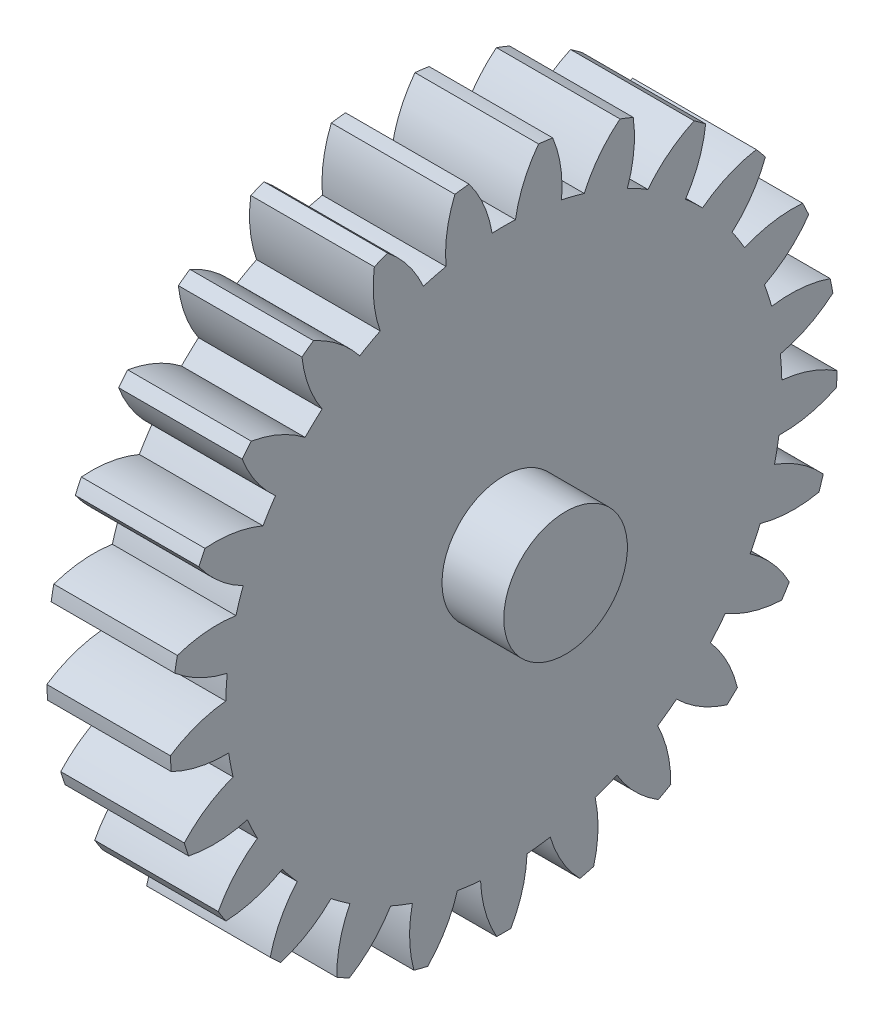
from build123d import *

# Parameters (mm, degrees)
SKETCH1_R                = 5
BOSS_EXTRUDE1_DEPTH      = 10
SKETCH2_R                = 5
BOSS_EXTRUDE2_DEPTH      = 5
BOSS_EXTRUDE2_DEPTH_BACK = 15


with BuildPart() as part:
    # Sketch1 → Boss-Extrude1 (new body)
    with BuildSketch(Plane(origin=(-8.184065019, 0, 0), x_dir=(0, 0, -1), z_dir=(1, 0, 0))):
        with BuildLine():
            ThreePointArc((-31.381707066, 6.680458214), (-29.386381489, 5.356012875), (-27.133369334, 4.54396864))
            ThreePointArc((-27.133369334, 4.54396864), (-27.212642826, 3.600930631), (-27.252188432, 2.655393156))
            ThreePointArc((-27.252188432, 2.655393156), (-29.589211043, 2.132129431), (-31.734799899, 1.068208346))
            ThreePointArc((-31.734799899, 1.068208346), (-31.70476113, 0.492862705), (-31.662453104, -0.081711019))
            ThreePointArc((-31.662453104, -0.081711019), (-29.400438188, -0.86832918), (-27.016261363, -1.094560213))
            ThreePointArc((-27.016261363, -1.094560213), (-26.858520317, -2.027685464), (-26.661677917, -2.953351734))
            ThreePointArc((-26.661677917, -2.953351734), (-28.795148269, -4.041370056), (-30.60874309, -5.605452354))
            ThreePointArc((-30.60874309, -5.605452354), (-30.436565403, -6.155252116), (-30.252695887, -6.701252972))
            ThreePointArc((-30.252695887, -6.701252972), (-27.866122347, -6.900617842), (-25.500587451, -6.526820746))
            ThreePointArc((-25.500587451, -6.526820746), (-25.115743316, -7.391401548), (-24.694881242, -8.239033595))
            ThreePointArc((-24.694881242, -8.239033595), (-26.490745546, -9.823442323), (-27.858391501, -11.789408791))
            ThreePointArc((-27.858391501, -11.789408791), (-27.554893451, -12.279116732), (-27.241015643, -12.762237478))
            ThreePointArc((-27.241015643, -12.762237478), (-24.879840672, -12.36182223), (-22.681582963, -11.411484051))
            ThreePointArc((-22.681582963, -11.411484051), (-22.093816912, -12.153195613), (-21.475379476, -12.869533599))
            ThreePointArc((-21.475379476, -12.869533599), (-22.820796972, -14.850778503), (-23.656559836, -17.095100238))
            ThreePointArc((-23.656559836, -17.095100238), (-23.240811323, -17.493946208), (-22.816647319, -17.88383059))
            ThreePointArc((-22.816647319, -17.88383059), (-20.629232225, -16.908794787), (-18.736376318, -15.441628767))
            ThreePointArc((-18.736376318, -15.441628767), (-17.982619854, -16.013866624), (-17.205465754, -16.553900399))
            ThreePointArc((-17.205465754, -16.553900399), (-18.015898914, -18.807492577), (-18.267264631, -21.189150589))
            ThreePointArc((-18.267264631, -21.189150589), (-17.765388663, -21.472073629), (-17.257590249, -21.744223778))
            ThreePointArc((-17.257590249, -21.744223778), (-15.381378366, -20.255832504), (-13.912859361, -18.364026081))
            ThreePointArc((-13.912859361, -18.364026081), (-13.040473774, -18.730834424), (-12.153434461, -19.060631679))
            ThreePointArc((-12.153434461, -19.060631679), (-12.377960788, -21.444969646), (-12.029135127, -23.814315604))
            ThreePointArc((-12.029135127, -23.814315604), (-11.472666416, -23.963538618), (-10.913140433, -24.10085434))
            ThreePointArc((-10.913140433, -24.10085434), (-9.466021055, -22.192628693), (-8.514111399, -19.995051022))
            ThreePointArc((-8.514111399, -19.995051022), (-7.577911885, -20.133381932), (-6.636723301, -20.232220294))
            ThreePointArc((-6.636723301, -20.232220294), (-6.261234981, -22.597487326), (-5.33413594, -24.80564651))
            ThreePointArc((-5.33413594, -24.80564651), (-4.758039463, -24.811793268), (-4.181942985, -24.80564651))
            ThreePointArc((-4.181942985, -24.80564651), (-3.254843944, -22.597487326), (-2.879355625, -20.232220294))
            ThreePointArc((-2.879355625, -20.232220294), (-1.938167041, -20.133381932), (-1.001967526, -19.995051022))
            ThreePointArc((-1.001967526, -19.995051022), (-0.050057871, -22.192628693), (1.397061507, -24.10085434))
            ThreePointArc((1.397061507, -24.10085434), (1.956587491, -23.963538618), (2.513056201, -23.814315604))
            ThreePointArc((2.513056201, -23.814315604), (2.861881863, -21.444969646), (2.637355535, -19.060631679))
            ThreePointArc((2.637355535, -19.060631679), (3.524394848, -18.730834424), (4.396780435, -18.364026081))
            ThreePointArc((4.396780435, -18.364026081), (5.865299441, -20.255832504), (7.741511323, -21.744223778))
            ThreePointArc((7.741511323, -21.744223778), (8.249309738, -21.472073629), (8.751185706, -21.189150589))
            ThreePointArc((8.751185706, -21.189150589), (8.499819989, -18.807492577), (7.689386829, -16.553900399))
            ThreePointArc((7.689386829, -16.553900399), (8.466540929, -16.013866624), (9.220297393, -15.441628767))
            ThreePointArc((9.220297393, -15.441628767), (11.1131533, -16.908794787), (13.300568394, -17.88383059))
            ThreePointArc((13.300568394, -17.88383059), (13.724732397, -17.493946208), (14.14048091, -17.095100238))
            ThreePointArc((14.14048091, -17.095100238), (13.304718047, -14.850778503), (11.959300551, -12.869533599))
            ThreePointArc((11.959300551, -12.869533599), (12.577737987, -12.153195613), (13.165504038, -11.411484051))
            ThreePointArc((13.165504038, -11.411484051), (15.363761747, -12.36182223), (17.724936717, -12.762237478))
            ThreePointArc((17.724936717, -12.762237478), (18.038814526, -12.279116732), (18.342312575, -11.789408791))
            ThreePointArc((18.342312575, -11.789408791), (16.974666621, -9.823442323), (15.178802317, -8.239033595))
            ThreePointArc((15.178802317, -8.239033595), (15.599664391, -7.391401548), (15.984508526, -6.526820746))
            ThreePointArc((15.984508526, -6.526820746), (18.350043421, -6.900617842), (20.736616961, -6.701252972))
            ThreePointArc((20.736616961, -6.701252972), (20.920486477, -6.155252116), (21.092664165, -5.605452354))
            ThreePointArc((21.092664165, -5.605452354), (19.279069343, -4.041370056), (17.145598992, -2.953351734))
            ThreePointArc((17.145598992, -2.953351734), (17.342441391, -2.027685464), (17.500182438, -1.094560213))
            ThreePointArc((17.500182438, -1.094560213), (19.884359263, -0.86832918), (22.146374179, -0.081711019))
            ThreePointArc((22.146374179, -0.081711019), (22.188682205, 0.492862705), (22.218720973, 1.068208346))
            ThreePointArc((22.218720973, 1.068208346), (20.073132118, 2.132129431), (17.736109506, 2.655393156))
            ThreePointArc((17.736109506, 2.655393156), (17.6965639, 3.600930631), (17.617290408, 4.54396864))
            ThreePointArc((17.617290408, 4.54396864), (19.870302564, 5.356012875), (21.86562814, 6.680458214))
            ThreePointArc((21.86562814, 6.680458214), (21.763716307, 7.247502226), (21.64972871, 7.812242663))
            ThreePointArc((21.64972871, 7.812242663), (19.306961059, 8.309152461), (16.913229914, 8.234783004))
            ThreePointArc((16.913229914, 8.234783004), (16.639781097, 9.140780089), (16.328474112, 10.034476309))
            ThreePointArc((16.328474112, 10.034476309), (18.308756558, 11.38131002), (19.912019151, 13.160362765))
            ThreePointArc((19.912019151, 13.160362765), (19.672290954, 13.684247605), (19.421439251, 14.20289812))
            ThreePointArc((19.421439251, 14.20289812), (17.028697513, 14.10157396), (14.728664765, 13.434244228))
            ThreePointArc((14.728664765, 13.434244228), (14.238494533, 14.243773793), (13.714714617, 15.031974003))
            ThreePointArc((13.714714617, 15.031974003), (15.297838925, 16.828970675), (16.408299649, 18.9508464))
            ThreePointArc((16.408299649, 18.9508464), (16.045818092, 19.398654456), (15.673864219, 19.838626329))
            ThreePointArc((15.673864219, 19.838626329), (13.381493156, 19.145434781), (11.319678322, 17.927075556))
            ThreePointArc((11.319678322, 17.927075556), (10.643585874, 18.589271881), (9.940244045, 19.222450564))
            ThreePointArc((9.940244045, 19.222450564), (11.026736693, 21.356698286), (11.574621216, 23.688071736))
            ThreePointArc((11.574621216, 23.688071736), (11.112162349, 24.031665581), (10.642477535, 24.365313762))
            ThreePointArc((10.642477535, 24.365313762), (8.594515253, 23.1238106), (6.900469741, 21.430975871))
            ThreePointArc((6.900469741, 21.430975871), (6.080936451, 21.904230727), (5.242226264, 22.342602937))
            ThreePointArc((5.242226264, 22.342602937), (5.763818922, 24.679999077), (5.714701645, 27.074381482))
            ThreePointArc((5.714701645, 27.074381482), (5.18132346, 27.292171851), (4.643419729, 27.498531998))
            ThreePointArc((4.643419729, 27.498531998), (2.968547229, 25.786725432), (1.74871415, 23.725782232))
            ThreePointArc((1.74871415, 23.725782232), (0.837234309, 23.980359275), (-0.084144991, 24.196380475))
            ThreePointArc((-0.084144991, 24.196380475), (-0.160225908, 26.590057835), (-0.803258765, 28.897001345))
            ThreePointArc((-0.803258765, 28.897001345), (-1.374042156, 28.975303668), (-1.946366334, 29.041409413))
            ThreePointArc((-1.946366334, 29.041409413), (-3.142910653, 26.966858545), (-3.8118847, 24.667303515))
            ThreePointArc((-3.8118847, 24.667303515), (-4.758039463, 24.687206732), (-5.704194225, 24.667303515))
            ThreePointArc((-5.704194225, 24.667303515), (-6.373168273, 26.966858545), (-7.569712591, 29.041409413))
            ThreePointArc((-7.569712591, 29.041409413), (-8.142036769, 28.975303668), (-8.71282016, 28.897001345))
            ThreePointArc((-8.71282016, 28.897001345), (-9.355853018, 26.590057835), (-9.431933935, 24.196380475))
            ThreePointArc((-9.431933935, 24.196380475), (-10.353313234, 23.980359275), (-11.264793076, 23.725782232))
            ThreePointArc((-11.264793076, 23.725782232), (-12.484626154, 25.786725432), (-14.159498654, 27.498531998))
            ThreePointArc((-14.159498654, 27.498531998), (-14.697402385, 27.292171851), (-15.230780571, 27.074381482))
            ThreePointArc((-15.230780571, 27.074381482), (-15.279897847, 24.679999077), (-14.75830519, 22.342602937))
            ThreePointArc((-14.75830519, 22.342602937), (-15.597015376, 21.904230727), (-16.416548667, 21.430975871))
            ThreePointArc((-16.416548667, 21.430975871), (-18.110594178, 23.1238106), (-20.15855646, 24.365313762))
            ThreePointArc((-20.15855646, 24.365313762), (-20.628241275, 24.031665581), (-21.090700141, 23.688071736))
            ThreePointArc((-21.090700141, 23.688071736), (-20.542815618, 21.356698286), (-19.456322971, 19.222450564))
            ThreePointArc((-19.456322971, 19.222450564), (-20.159664799, 18.589271881), (-20.835757248, 17.927075556))
            ThreePointArc((-20.835757248, 17.927075556), (-22.897572081, 19.145434781), (-25.189943144, 19.838626329))
            ThreePointArc((-25.189943144, 19.838626329), (-25.561897018, 19.398654456), (-25.924378574, 18.9508464))
            ThreePointArc((-25.924378574, 18.9508464), (-24.813917851, 16.828970675), (-23.230793543, 15.031974003))
            ThreePointArc((-23.230793543, 15.031974003), (-23.754573459, 14.243773793), (-24.24474369, 13.434244228))
            ThreePointArc((-24.24474369, 13.434244228), (-26.544776438, 14.10157396), (-28.937518176, 14.20289812))
            ThreePointArc((-28.937518176, 14.20289812), (-29.188369879, 13.684247605), (-29.428098076, 13.160362765))
            ThreePointArc((-29.428098076, 13.160362765), (-27.824835484, 11.38131002), (-25.844553037, 10.034476309))
            ThreePointArc((-25.844553037, 10.034476309), (-26.155860023, 9.140780089), (-26.429308839, 8.234783004))
            ThreePointArc((-26.429308839, 8.234783004), (-28.823039984, 8.309152461), (-31.165807635, 7.812242663))
            ThreePointArc((-31.165807635, 7.812242663), (-31.279795232, 7.247502226), (-31.381707066, 6.680458214))
        make_face()
        with Locations((-4.758039463, 2.188206732)):
            Circle(SKETCH1_R, mode=Mode.SUBTRACT)
    extrude(amount=-BOSS_EXTRUDE1_DEPTH)

    # Sketch2 → Boss-Extrude2 (add, two sides)
    with BuildSketch(Plane.ZY.offset(18.184065019)) as boss_extrude2_sk:
        with Locations((4.758039463, 2.188206732)):
            Circle(SKETCH2_R)
    extrude(amount=BOSS_EXTRUDE2_DEPTH)
    extrude(boss_extrude2_sk.sketch, amount=-BOSS_EXTRUDE2_DEPTH_BACK)


solid = part.part
